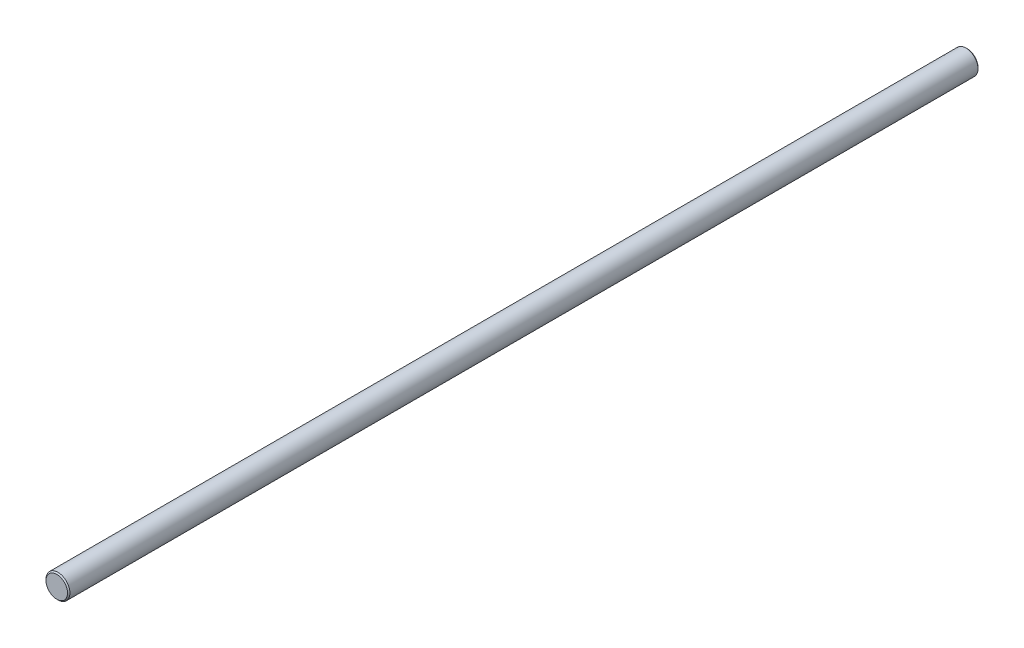
from build123d import *

# Parameters (mm, degrees)
SKETCH1_R           = 5
BOSS_EXTRUDE1_DEPTH = 380
CHAMFER1_SIZE       = 0.5


with BuildPart() as part:
    # Sketch1 → Boss-Extrude1 (new body)
    with BuildSketch(Plane.XY):
        Circle(SKETCH1_R)
    extrude(amount=-BOSS_EXTRUDE1_DEPTH)

    # Chamfer1
    chamfer1_edges = [part.edges().sort_by_distance(p)[0] for p in [
        (-5, 0, 0),
        (-5, 0, -380),
    ]]
    chamfer(chamfer1_edges, length=CHAMFER1_SIZE)


solid = part.part
